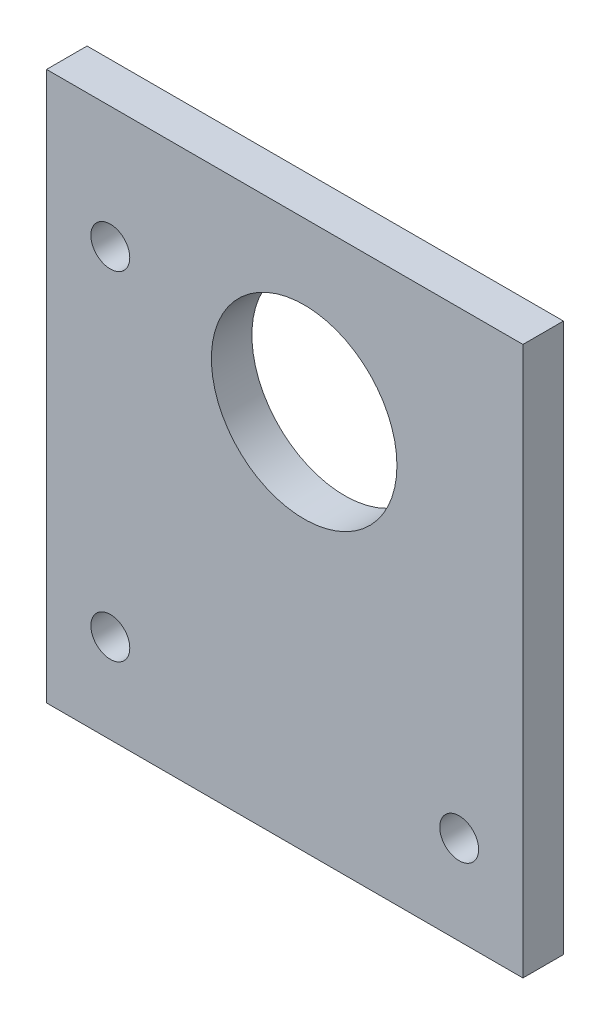
from build123d import *

# Parameters (mm, degrees)
SKETCH1_W           = 74.667436935
SKETCH1_H           = 86.002396902
SKETCH1_R           = 14.5415
SKETCH1_R_2         = 3.048
BOSS_EXTRUDE1_DEPTH = 6.35


with BuildPart() as part:
    # Sketch1 → Boss-Extrude1 (new body)
    with BuildSketch(Plane.XY):
        with Locations((-3.043718468, -16.688801549)):
            Rectangle(SKETCH1_W, SKETCH1_H)
        Circle(SKETCH1_R, mode=Mode.SUBTRACT)
        with Locations((-30.382536935, 7.262396902)):
            Circle(SKETCH1_R_2, mode=Mode.SUBTRACT)
        with Locations((24.2951, -45.72)):
            Circle(SKETCH1_R_2, mode=Mode.SUBTRACT)
        with Locations((-30.382536935, -45.72)):
            Circle(SKETCH1_R_2, mode=Mode.SUBTRACT)
    extrude(amount=BOSS_EXTRUDE1_DEPTH)


solid = part.part
